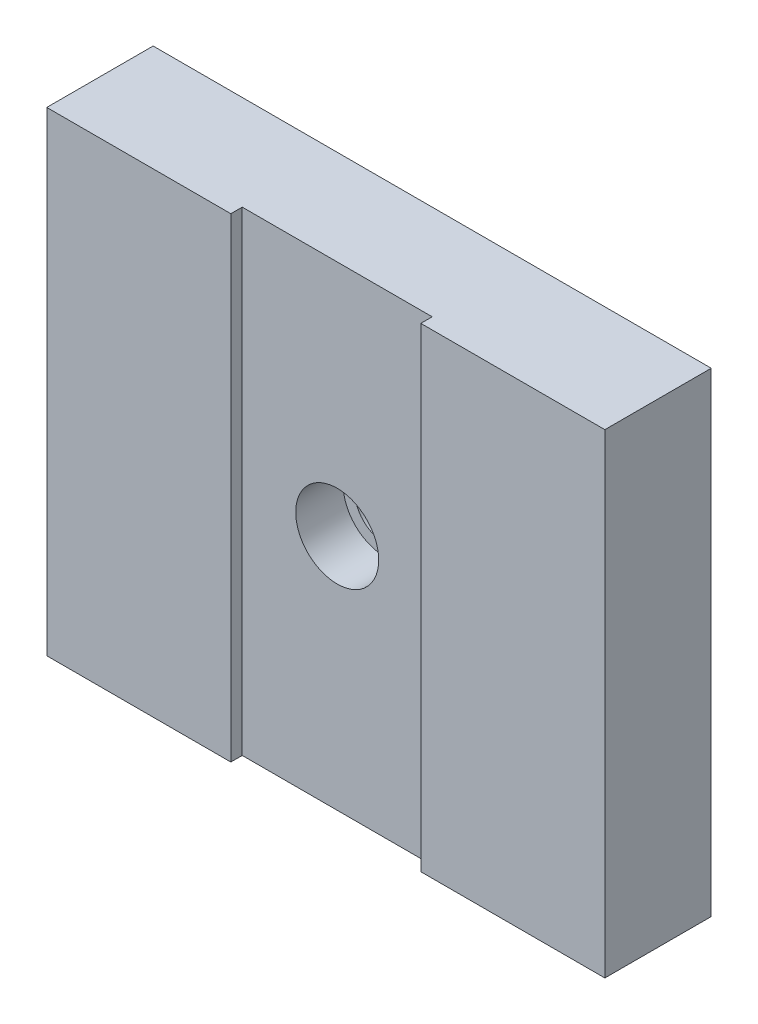
from build123d import *

# Parameters (mm, degrees)
SKETCH1_W                                        = 74.6252
SKETCH1_H                                        = 63.5
BOSS_EXTRUDE1_DEPTH                              = 14.224
CBORE_FOR_1_4_SOCKET_HEAD_CAP_SCREW1_D           = 8.0264
CBORE_FOR_1_4_SOCKET_HEAD_CAP_SCREW1_CBORE_D     = 11.0998
CBORE_FOR_1_4_SOCKET_HEAD_CAP_SCREW1_CBORE_DEPTH = 7.874
SKETCH9_W                                        = 25.4
SKETCH9_H                                        = 63.5
CUT_EXTRUDE1_DEPTH                               = 1.524
SKETCH10_R                                       = 11.1125
CUT_EXTRUDE2_DEPTH                               = 1.397


with BuildPart() as part:
    # Sketch1 → Boss-Extrude1 (new body)
    with BuildSketch(Plane.XY):
        with Locations((37.3126, 31.75)):
            Rectangle(SKETCH1_W, SKETCH1_H)
    extrude(amount=BOSS_EXTRUDE1_DEPTH)

    # CBORE for 1/4 Socket Head Cap Screw1 (through all)
    with Locations(Plane.XY.offset(14.224)):
        with Locations((37.3126, 31.75)):
            CounterBoreHole(CBORE_FOR_1_4_SOCKET_HEAD_CAP_SCREW1_D / 2, CBORE_FOR_1_4_SOCKET_HEAD_CAP_SCREW1_CBORE_D / 2, CBORE_FOR_1_4_SOCKET_HEAD_CAP_SCREW1_CBORE_DEPTH)

    # Sketch9 → Cut-Extrude1 (cut)
    with BuildSketch(Plane.XY.offset(14.224)):
        with Locations((37.3126, 31.75)):
            Rectangle(SKETCH9_W, SKETCH9_H)
    extrude(amount=-CUT_EXTRUDE1_DEPTH, mode=Mode.SUBTRACT)

    # Sketch10 → Cut-Extrude2 (cut)
    with BuildSketch(Plane(origin=(0, 0, 0), x_dir=(-1, 0, 0), z_dir=(0, 0, -1))):
        with Locations((-37.3126, 31.75)):
            Circle(SKETCH10_R)
    extrude(amount=-CUT_EXTRUDE2_DEPTH, mode=Mode.SUBTRACT)


solid = part.part
